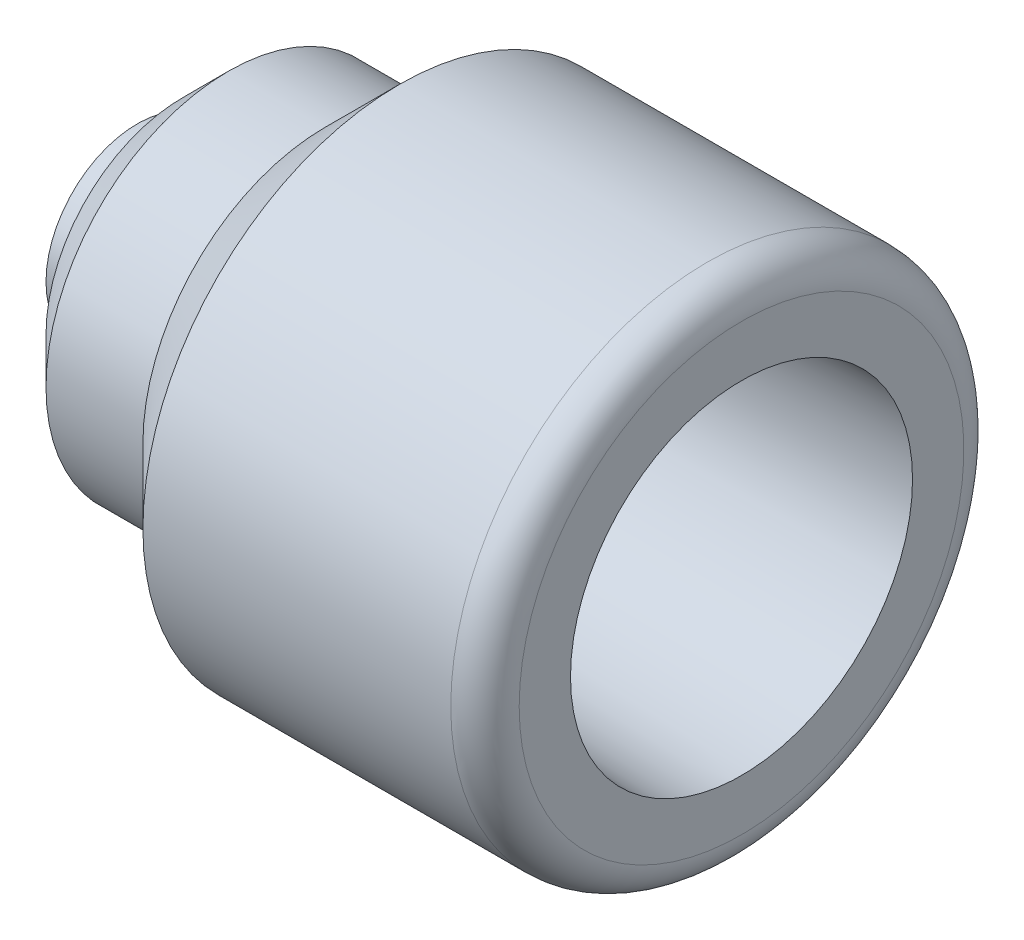
from build123d import *


with BuildPart() as part:
    # Sketch1 → Revolve1 (revolve)
    with BuildSketch(Plane.XY):
        with BuildLine():
            Line((0, 8), (4, 8))
            Line((4, 8), (4, 12))
            Line((4, 12), (8, 16))
            Line((8, 16), (16.5, 16))
            Line((16.5, 16), (23, 22.5))
            Line((23, 22.5), (50, 22.5))
            ThreePointArc((50, 22.5), (52.121320344, 21.621320344), (53, 19.5))
            Line((53, 19.5), (53, 15))
            Line((53, 15), (25.772080403, 14.049180096))
            ThreePointArc((25.772080403, 14.049180096), (25.22452816, 13.805394131), (25, 13.249667434))
            Line((25, 13.249667434), (25, 5.1))
            Line((25, 5.1), (0, 5.1))
            Line((0, 5.1), (0, 8))
        make_face()
    revolve(axis=Axis((0, 0, 0), (1, 0, 0)))


solid = part.part
